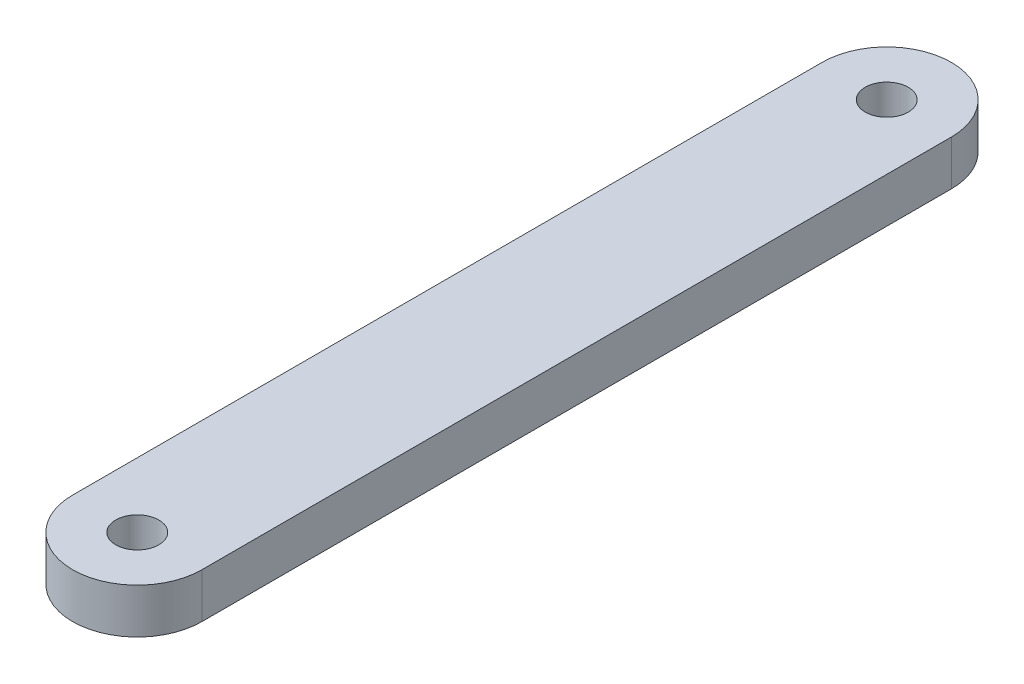
from build123d import *

# Parameters (mm, degrees)
SKETCH1_R           = 1.4605
BOSS_EXTRUDE1_DEPTH = 3.048


with BuildPart() as part:
    # Sketch1 → Boss-Extrude1 (new body)
    with BuildSketch(Plane(origin=(0, 0, 0), x_dir=(1, 0, 0), z_dir=(0, 1, 0))):
        with BuildLine():
            Line((-4.3815, 50.8), (-4.3815, 0))
            ThreePointArc((-4.3815, 0), (0, -4.3815), (4.3815, 0))
            Line((4.3815, 0), (4.3815, 50.8))
            ThreePointArc((4.3815, 50.8), (0, 55.1815), (-4.3815, 50.8))
        make_face()
        Circle(SKETCH1_R, mode=Mode.SUBTRACT)
        with Locations((0, 50.8)):
            Circle(SKETCH1_R, mode=Mode.SUBTRACT)
    extrude(amount=BOSS_EXTRUDE1_DEPTH)


solid = part.part
